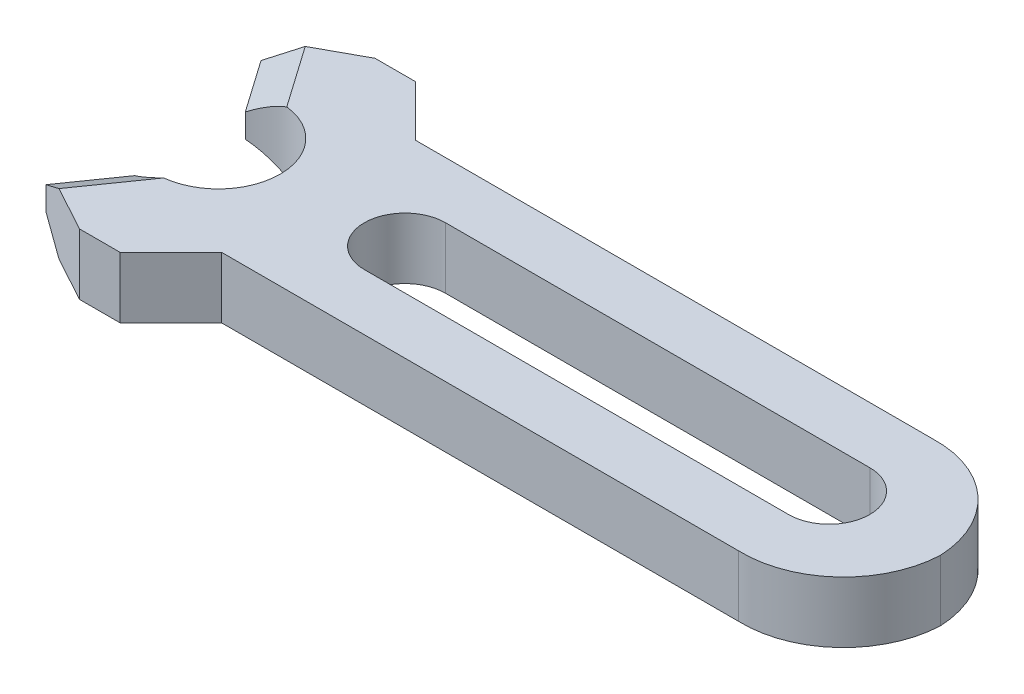
from build123d import *

# Parameters (mm, degrees)
BOSS_EXTRUDE1_DEPTH = 3.8227
CHAMFER1_SIZE       = 1.17
CHAMFER1_SIZE2      = 2.026499445


with BuildPart() as part:
    # Sketch1 → Boss-Extrude1 (new body)
    with BuildSketch(Plane(origin=(0, 0, 0), x_dir=(1, 0, 0), z_dir=(0, 1, 0))):
        with BuildLine():
            ThreePointArc((13.950769004, 0.075877145), (11.919896105, 4.457709898), (7.394873867, 6.145630734))
            Line((7.394873867, 6.145630734), (-24.953822463, 6.145630734))
            Line((-24.953822463, 6.145630734), (-28.128822463, 9.320630734))
            Line((-28.128822463, 9.320630734), (-30.668822463, 9.320630734))
            Line((-30.668822463, 9.320630734), (-35.284454716, 6.802487588))
            Line((-35.284454716, 6.802487588), (-32.99014897, 3.525879411))
            ThreePointArc((-32.99014897, 3.525879411), (-29.206377785, 3.379332749), (-27.355545164, 0.075877145))
            Line((-27.355545164, 0.075877145), (-22.092646818, 0.075877145))
            ThreePointArc((-22.092646818, 0.075877145), (-21.348698042, 1.87192837), (-19.552646818, 2.615877145))
            Line((-19.552646818, 2.615877145), (6.926853182, 2.615877145))
            Line((6.926853182, 2.615877145), (6.990353182, 2.615877145))
            ThreePointArc((6.990353182, 2.615877145), (8.786404406, 1.87192837), (9.530353182, 0.075877145))
            Line((9.530353182, 0.075877145), (13.950769004, 0.075877145))
        make_face()
    extrude(amount=BOSS_EXTRUDE1_DEPTH)

    # Chamfer1
    chamfer1_edges = [part.edges().sort_by_distance(p)[0] for p in [
        (-34.137301843, 0, -5.1641835),
        (-34.137301843, 3.8227, -5.1641835),
    ]]
    chamfer1_side = [part.faces().sort_by_distance(p)[0] for p in [
        (-34.137301843, 1.91135, -5.1641835),
    ]]
    chamfer(chamfer1_edges, length=CHAMFER1_SIZE, length2=CHAMFER1_SIZE2, reference=chamfer1_side[0])

    # Mirror1: part across plane


with BuildPart() as part_1:
    add(part.part)
    add(part.part.mirror(Plane(origin=(0, 3.8227, -0.075877145), x_dir=(1, 0, 0), z_dir=(0, 0, 1))))


solid = part_1.part
